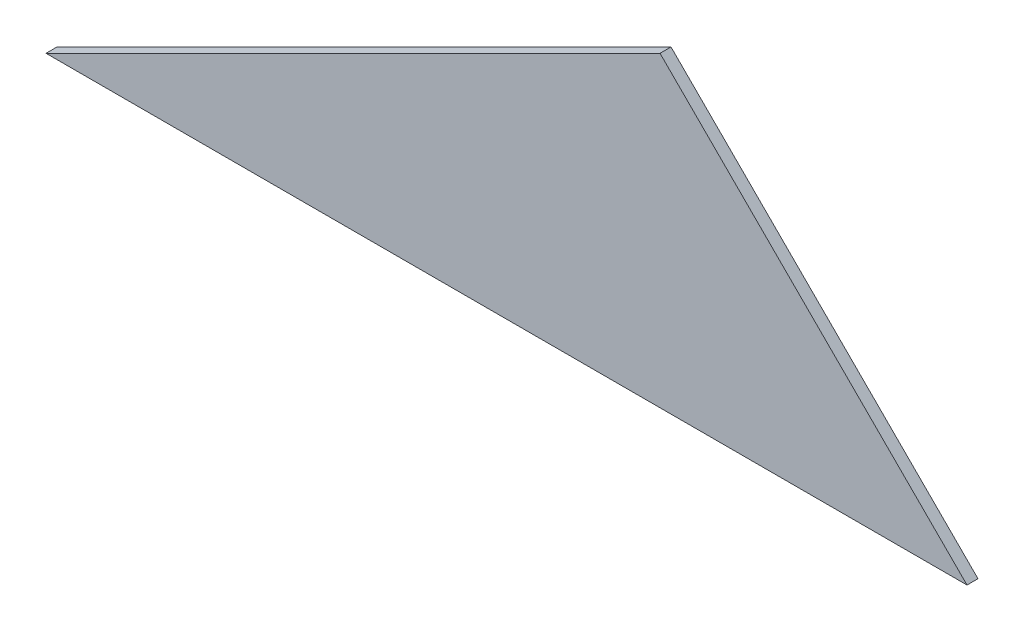
from build123d import *

# Parameters (mm, degrees)
BOSS_EXTRUDE1_DEPTH = 2.5


with BuildPart() as part:
    # Sketch2 → Boss-Extrude1 (new body)
    with BuildSketch(Plane.XY):
        Polygon((0, 0), (210, 0), (140, 70), align=None)
    extrude(amount=BOSS_EXTRUDE1_DEPTH)


solid = part.part
